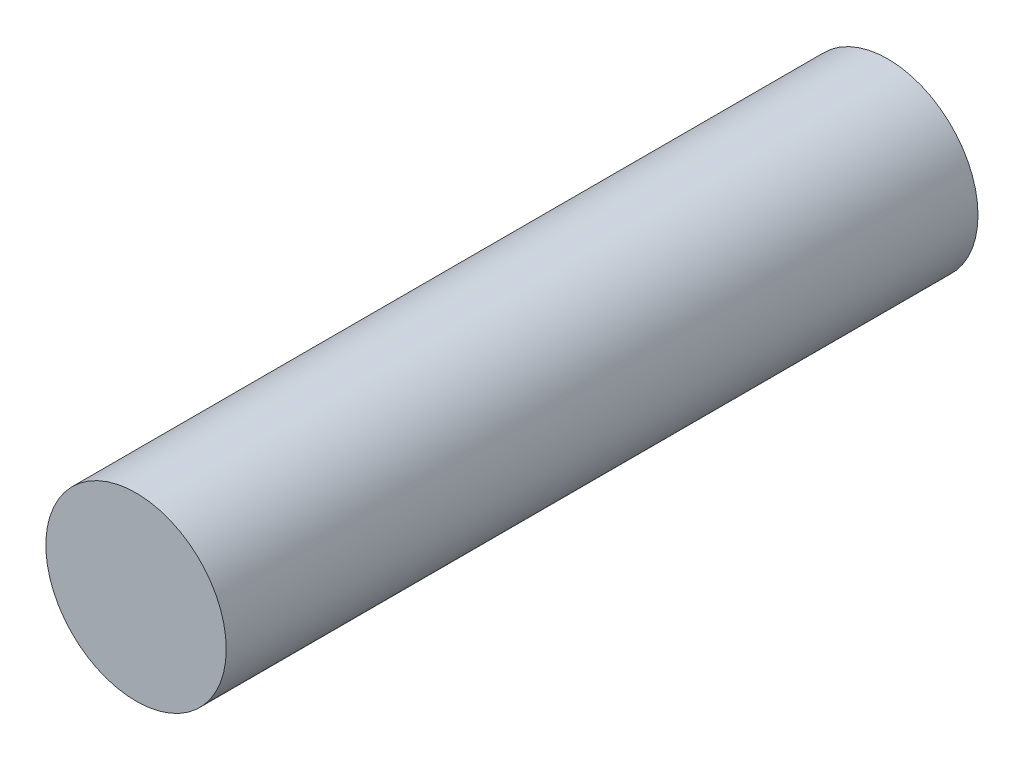
from build123d import *

# Parameters (mm, degrees)
SKETCH1_R           = 6
BOSS_EXTRUDE1_DEPTH = 50


with BuildPart() as part:
    # Sketch1 → Boss-Extrude1 (new body)
    with BuildSketch(Plane.XY):
        Circle(SKETCH1_R)
    extrude(amount=BOSS_EXTRUDE1_DEPTH)


solid = part.part
